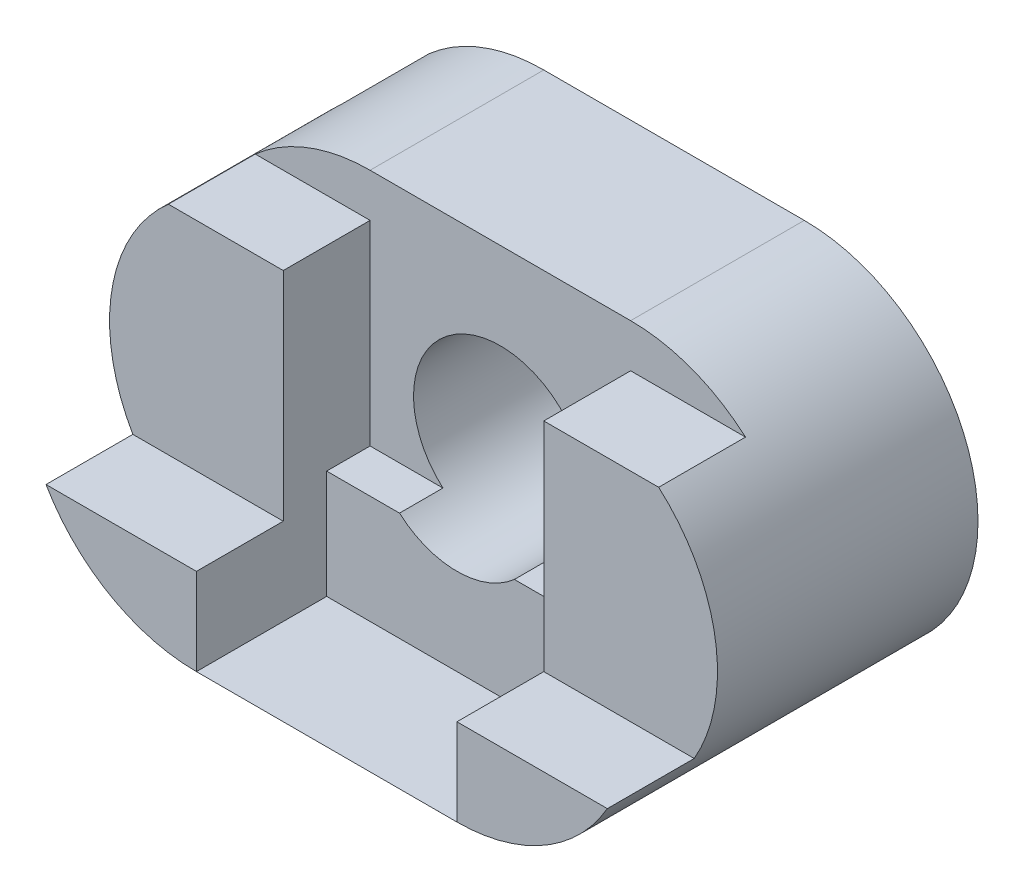
from build123d import *

# Parameters (mm, degrees)
BOSS_EXTRUDE1_DEPTH     = 80
SKETCH2_R               = 20
CUT_EXTRUDE1_DEPTH      = 80
CUT_EXTRUDE3_DEPTH      = 170
CUT_EXTRUDE3_DEPTH_BACK = 60
SKETCH4_W               = 20
SKETCH4_H               = 60
CUT_EXTRUDE4_DEPTH      = 170
CUT_EXTRUDE4_DEPTH_BACK = 170
SKETCH5_W               = 20
SKETCH5_H               = 10
SKETCH6_W               = 60
SKETCH6_H               = 25
CUT_EXTRUDE5_DEPTH      = 30
SKETCH7_W               = 60
SKETCH7_H               = 10
CUT_EXTRUDE6_DEPTH      = 62
SKETCH8_W               = 60
SKETCH8_H               = 25
BOSS_EXTRUDE2_DEPTH     = 30
CUT_EXTRUDE7_START      = -30
CUT_EXTRUDE7_DEPTH      = 30
CUT_EXTRUDE8_START      = -30
CUT_EXTRUDE8_DEPTH      = 30
CUT_EXTRUDE9_DEPTH      = 10
BOSS_EXTRUDE3_DEPTH     = 10
BOSS_EXTRUDE4_DEPTH     = 20
SKETCH18_W              = 37.195082215
SKETCH18_H              = 5
CUT_EXTRUDE23_DEPTH     = 20
CUT_EXTRUDE25_DEPTH     = 30
SKETCH21_W              = 30
SKETCH21_H              = 25.000260328
CUT_EXTRUDE31_DEPTH     = 30
CUT_EXTRUDE32_DEPTH     = 30
SKETCH26_W              = 10
SKETCH26_H              = 5.000052065
CUT_EXTRUDE33_DEPTH     = 57
SKETCH29_W              = 34.732287975
SKETCH29_H              = 30
CUT_EXTRUDE37_DEPTH     = 57
SKETCH30_W              = 34.732287975
SKETCH30_H              = 10
CUT_EXTRUDE38_DEPTH     = 57
SKETCH31_W              = 10
SKETCH31_H              = 0.158503964
CUT_EXTRUDE39_DEPTH     = 57
SKETCH32_W              = 0.091268964
SKETCH32_H              = 10
CUT_EXTRUDE40_DEPTH     = 57
BOSS_EXTRUDE6_DEPTH     = 30
BOSS_EXTRUDE7_DEPTH     = 10
SKETCH37_W              = 20
SKETCH37_H              = 70
CUT_EXTRUDE47_DEPTH     = 68
SKETCH45_W              = 60
SKETCH45_H              = 30
BOSS_EXTRUDE10_DEPTH    = 0.0001
BOSS_EXTRUDE11_START    = 20
BOSS_EXTRUDE11_DEPTH    = 20
SKETCH49_W              = 20
SKETCH49_H              = 70
CUT_EXTRUDE54_DEPTH     = 95


with BuildPart() as part:
    # Sketch1 → Boss-Extrude1 (new body)
    with BuildSketch(Plane.XY):
        with BuildLine():
            Line((0, 40), (60, 40))
            ThreePointArc((60, 40), (100, 0), (60, -40))
            Line((60, -40), (0, -40))
            ThreePointArc((0, -40), (-40, 0), (0, 40))
        make_face()
    extrude(amount=BOSS_EXTRUDE1_DEPTH)

    # Sketch2 → Cut-Extrude1 (cut)
    with BuildSketch(Plane.XY.offset(80)):
        with Locations((30, 0)):
            Circle(SKETCH2_R)
    extrude(amount=-CUT_EXTRUDE1_DEPTH, mode=Mode.SUBTRACT)

    # Sketch4 → Cut-Extrude3 (cut, two sides: drawn at the far end of the back side and taken through both)
    with BuildSketch(Plane(origin=(0, 0, 0), x_dir=(0, 0, -1), z_dir=(1, 0, 0)).offset(-CUT_EXTRUDE3_DEPTH_BACK)):
        with Locations((-70, 10)):
            Rectangle(SKETCH4_W, SKETCH4_H)
    extrude(amount=CUT_EXTRUDE3_DEPTH + CUT_EXTRUDE3_DEPTH_BACK, mode=Mode.SUBTRACT)

    # Sketch5 → Cut-Extrude4 (cut, two sides: drawn at the far end of the back side and taken through both)
    with BuildSketch(Plane(origin=(0, 0, 0), x_dir=(0, 0, -1), z_dir=(1, 0, 0)).offset(-CUT_EXTRUDE4_DEPTH_BACK)):
        with Locations((-50, 35)):
            Rectangle(SKETCH5_W, SKETCH5_H)
    extrude(amount=CUT_EXTRUDE4_DEPTH + CUT_EXTRUDE4_DEPTH_BACK, mode=Mode.SUBTRACT)

    # Sketch6 → Cut-Extrude5 (cut)
    with BuildSketch(Plane.XY.offset(80)):
        with Locations((30, -27.5)):
            Rectangle(SKETCH6_W, SKETCH6_H)
    extrude(amount=-CUT_EXTRUDE5_DEPTH, mode=Mode.SUBTRACT)

    # Sketch7 → Cut-Extrude6 (cut)
    with BuildSketch(Plane.XZ.offset(15)):
        with Locations((30, 55)):
            Rectangle(SKETCH7_W, SKETCH7_H)
    extrude(amount=-CUT_EXTRUDE6_DEPTH, mode=Mode.SUBTRACT)

    # Sketch8 → Boss-Extrude2 (add)
    with BuildSketch(Plane.XY.offset(50)):
        with Locations((30, -27.5)):
            Rectangle(SKETCH8_W, SKETCH8_H)
    extrude(amount=BOSS_EXTRUDE2_DEPTH)

    # Sketch9 → Cut-Extrude7 (cut)
    with BuildSketch(Plane(origin=(0, 0, 50), x_dir=(-1, 0, 0), z_dir=(0, 0, -1)).offset(CUT_EXTRUDE7_START)):
        with BuildLine():
            Line((-43.228756555, -15), (-16.771243445, -15))
            ThreePointArc((-16.771243445, -15), (-30, -20), (-43.228756555, -15))
        make_face()
    extrude(amount=CUT_EXTRUDE7_DEPTH, mode=Mode.SUBTRACT)

    # Sketch10 → Cut-Extrude8 (cut)
    with BuildSketch(Plane.XY.offset(80).offset(CUT_EXTRUDE8_START)):
        with BuildLine():
            Line((60, -20), (60, -40))
            ThreePointArc((60, -40), (80, -34.641016151), (94.641016151, -20))
            Line((94.641016151, -20), (60, -20))
        make_face()
    extrude(amount=CUT_EXTRUDE8_DEPTH, mode=Mode.SUBTRACT)

    # Sketch11 → Cut-Extrude9 (cut)
    with BuildSketch(Plane.XY.offset(50)):
        with BuildLine():
            Line((60, 30), (0, 30))
            Line((0, 30), (0, -15))
            Line((0, -15), (16.771243445, -15))
            ThreePointArc((16.771243445, -15), (30, 20), (43.228756555, -15))
            Line((43.228756555, -15), (60, -15))
            Line((60, -15), (60, 30))
        make_face()
    extrude(amount=-CUT_EXTRUDE9_DEPTH, mode=Mode.SUBTRACT)

    # Sketch12 → Boss-Extrude3 (add)
    with BuildSketch(Plane.XY.offset(50)):
        with BuildLine():
            Line((60, -20), (94.641016151, -20))
            ThreePointArc((94.641016151, -20), (80, -34.641016151), (60, -40))
            Line((60, -40), (60, -20))
        make_face()
    extrude(amount=BOSS_EXTRUDE3_DEPTH)

    # Sketch17 → Boss-Extrude4 (add)
    with BuildSketch(Plane.XY.offset(60)):
        with BuildLine():
            Line((97.080992435, -15), (60, -15))
            Line((60, -15), (60, -40))
            ThreePointArc((60, -40), (82.360679775, -33.166247904), (97.080992435, -15))
        make_face()
    extrude(amount=BOSS_EXTRUDE4_DEPTH)

    # Sketch18 → Cut-Extrude23 (cut)
    with BuildSketch(Plane.XY.offset(80)):
        with Locations((78.483451328, -17.5)):
            Rectangle(SKETCH18_W, SKETCH18_H)
    extrude(amount=-CUT_EXTRUDE23_DEPTH, mode=Mode.SUBTRACT)

    # Sketch19 → Cut-Extrude25 (cut)
    with BuildSketch(Plane.XY.offset(80)):
        with BuildLine():
            Line((16.771243445, -15), (0, -15))
            Line((0, -15), (0, -20))
            Line((0, -20), (0, -40))
            Line((0, -40), (60, -40))
            Line((60, -40), (59.908728176, -20))
            Line((59.908728176, -20), (59.88591022, -20))
            Line((59.88591022, -20), (59.88591022, -15))
            Line((59.88591022, -15), (43.228756555, -15))
            ThreePointArc((43.228756555, -15), (30, -20), (16.771243445, -15))
        make_face()
    extrude(amount=-CUT_EXTRUDE25_DEPTH, mode=Mode.SUBTRACT)

    # Sketch21 → Cut-Extrude31 (cut)
    with BuildSketch(Plane(origin=(59.816210597, 0.272976733, 0), x_dir=(0, 0, 1), z_dir=(-0.999989586980257, -0.004563543694874004, 0))):
        with Locations((65, -27.773265937)):
            Rectangle(SKETCH21_W, SKETCH21_H)
    extrude(amount=CUT_EXTRUDE31_DEPTH, mode=Mode.SUBTRACT)

    # Sketch24 → Cut-Extrude32 (cut)
    with BuildSketch(Plane.XY.offset(50)):
        with BuildLine():
            Line((59.88591022, -15), (97.080992435, -15))
            ThreePointArc((97.080992435, -15), (98.92976522, 9.1909401), (86.456775103, 30.000650845))
            Line((86.456775103, 30.000650845), (59.88591022, 30.000650845))
            Line((59.88591022, 30.000650845), (59.88591022, -15))
        make_face()
    extrude(amount=CUT_EXTRUDE32_DEPTH, mode=Mode.SUBTRACT)

    # Sketch26 → Cut-Extrude33 (cut)
    with BuildSketch(Plane(origin=(59.816210597, 0.272976733, 0), x_dir=(0, 0, 1), z_dir=(-0.9999895869802571, -0.0045635436948740045, 0))):
        with Locations((55, -17.773161806)):
            Rectangle(SKETCH26_W, SKETCH26_H)
    extrude(amount=-CUT_EXTRUDE33_DEPTH, mode=Mode.SUBTRACT)

    # Sketch29 → Cut-Extrude37 (cut)
    with BuildSketch(Plane(origin=(0, -20, 0), x_dir=(1, 0, 0), z_dir=(0, 1, 0))):
        with Locations((77.274872164, -65)):
            Rectangle(SKETCH29_W, SKETCH29_H)
    extrude(amount=-CUT_EXTRUDE37_DEPTH, mode=Mode.SUBTRACT)

    # Sketch30 → Cut-Extrude38 (cut)
    with BuildSketch(Plane.XZ.offset(20)):
        with Locations((77.274872164, 55)):
            Rectangle(SKETCH30_W, SKETCH30_H)
    extrude(amount=-CUT_EXTRUDE38_DEPTH, mode=Mode.SUBTRACT)

    # Sketch31 → Cut-Extrude39 (cut)
    with BuildSketch(Plane.ZY.offset(-94.641016151)):
        with Locations((55, -19.920748018)):
            Rectangle(SKETCH31_W, SKETCH31_H)
    extrude(amount=-CUT_EXTRUDE39_DEPTH, mode=Mode.SUBTRACT)

    # Sketch32 → Cut-Extrude40 (cut)
    with BuildSketch(Plane(origin=(0.092517579, -20.272976733, 0), x_dir=(0.9999895869802571, 0.0045635436948740045, 0), z_dir=(-0.004563543694874004, 0.999989586980257, 0))):
        with Locations((94.5951176, -55)):
            Rectangle(SKETCH32_W, SKETCH32_H)
    extrude(amount=-CUT_EXTRUDE40_DEPTH, mode=Mode.SUBTRACT)

    # Sketch33 → Boss-Extrude6 (add)
    with BuildSketch(Plane.XY.offset(50)):
        with BuildLine():
            Line((60, -20), (60, -40))
            ThreePointArc((60, -40), (80, -34.641016151), (94.641016151, -20))
            Line((94.641016151, -20), (60, -20))
        make_face()
    extrude(amount=BOSS_EXTRUDE6_DEPTH)

    # Sketch34 → Boss-Extrude7 (add)
    with BuildSketch(Plane.XY.offset(50)):
        with BuildLine():
            Line((60, 30), (60, -20))
            Line((60, -20), (94.641016151, -20))
            ThreePointArc((94.641016151, -20), (99.474771304, 6.46083822), (86.457513111, 30))
            Line((86.457513111, 30), (60, 30))
        make_face()
    extrude(amount=BOSS_EXTRUDE7_DEPTH)

    # Sketch37 → Cut-Extrude47 (cut)
    with BuildSketch(Plane(origin=(0, 0, 0), x_dir=(0, 0, -1), z_dir=(1, 0, 0))):
        with Locations((-10, -5)):
            Rectangle(SKETCH37_W, SKETCH37_H)
    extrude(amount=-CUT_EXTRUDE47_DEPTH, mode=Mode.SUBTRACT)

    # Sketch45 → Boss-Extrude10 (add)
    with BuildSketch(Plane(origin=(0, -40, 0), x_dir=(-1, 0, 0), z_dir=(0, -1, 0))):
        with Locations((-30, -65)):
            Rectangle(SKETCH45_W, SKETCH45_H)
    extrude(amount=-BOSS_EXTRUDE10_DEPTH)

    # Sketch46 → Boss-Extrude11 (add)
    with BuildSketch(Plane(origin=(0, 0, 20), x_dir=(-1, 0, 0), z_dir=(0, 0, -1)).offset(BOSS_EXTRUDE11_START)):
        with BuildLine():
            Line((26.457513111, 30), (0, 30))
            Line((0, 30), (0, -40))
            ThreePointArc((0, -40), (37.416573868, -14.142135624), (26.457513111, 30))
        make_face()
    extrude(amount=-BOSS_EXTRUDE11_DEPTH)

    # Sketch49 → Cut-Extrude54 (cut)
    with BuildSketch(Plane(origin=(0, 0, 0), x_dir=(0, 0, -1), z_dir=(1, 0, 0))):
        with Locations((-10, -5)):
            Rectangle(SKETCH49_W, SKETCH49_H)
    extrude(amount=-CUT_EXTRUDE54_DEPTH, mode=Mode.SUBTRACT)


solid = part.part
